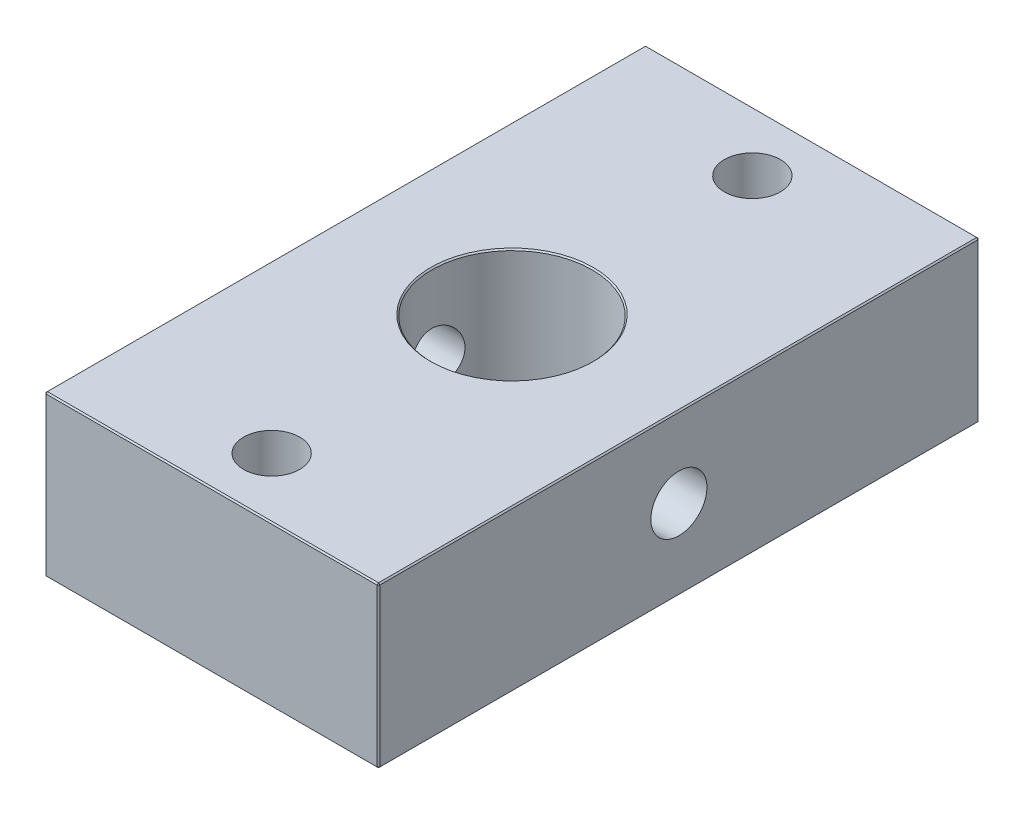
from build123d import *

# Parameters (mm, degrees)
SKETCH1_W           = 25
SKETCH1_H           = 45
SKETCH1_R           = 6
BOSS_EXTRUDE1_DEPTH = 12
M5_TAPPED_HOLE2_D   = 4.2
M5_TAPPED_HOLE3_D   = 4.2
CHAMFER1_SIZE       = 0.1


with BuildPart() as part:
    # Sketch1 → Boss-Extrude1 (new body)
    with BuildSketch(Plane(origin=(0, 0, 0), x_dir=(1, 0, 0), z_dir=(0, 1, 0))):
        Rectangle(SKETCH1_W, SKETCH1_H)
        Circle(SKETCH1_R, mode=Mode.SUBTRACT)
    extrude(amount=BOSS_EXTRUDE1_DEPTH)

    # M5 Tapped Hole2 (through all)
    with Locations(Plane(origin=(0, 12, 0), x_dir=(1, 0, 0), z_dir=(0, 1, 0))):
        with Locations((0, 18), (0, -18)):
            Hole(M5_TAPPED_HOLE2_D / 2)

    # M5 Tapped Hole3 (through all)
    with Locations(Plane.ZY.offset(12.5)):
        with Locations((0, 6)):
            Hole(M5_TAPPED_HOLE3_D / 2)

    # Chamfer1
    chamfer1_edges = [part.edges().sort_by_distance(p)[0] for p in [
        (-6, 0, 0),
        (-6, 12, 0),
        (-12.5, 12, 0),
        (0, 12, 22.5),
        (12.5, 12, 0),
        (0, 0, 22.5),
        (-12.5, 0, 0),
        (0, 0, -22.5),
        (12.5, 0, 0),
        (12.5, 6, 22.5),
        (-12.5, 6, 22.5),
        (-12.5, 6, -22.5),
        (12.5, 6, -22.5),
        (0, 12, -22.5),
    ]]
    chamfer(chamfer1_edges, length=CHAMFER1_SIZE)


solid = part.part
